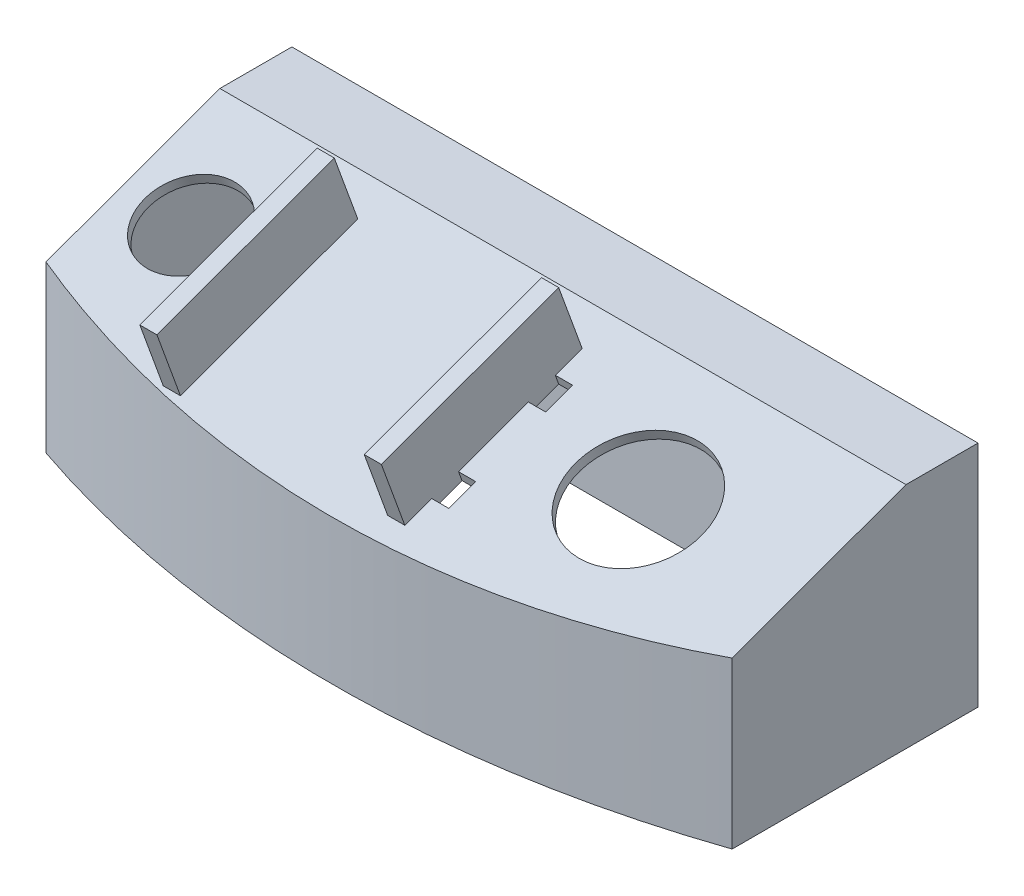
from build123d import *

# Parameters (mm, degrees)
BOSS_EXTRUDE1_DEPTH      = 40
CUT_EXTRUDE1_DEPTH       = 121
SKETCH3_R                = 11
SKETCH3_R_2              = 8.1
CUT_EXTRUDE3_DEPTH       = 1.75
SKETCH5_R                = 15
CUT_EXTRUDE4_DEPTH       = 41.144838819
CUT_EXTRUDE7_DEPTH       = 116.5
SKETCH11_W               = 3
SKETCH11_H               = 33
BOSS_EXTRUDE2_DEPTH      = 12
BOSS_EXTRUDE2_DEPTH_BACK = 1.75
CUT_EXTRUDE8_REACH       = 51.224
BOSS_EXTRUDE3_DEPTH      = 3


with BuildPart() as part:
    # Sketch1 → Boss-Extrude1 (new body)
    with BuildSketch(Plane(origin=(0, 0, 0), x_dir=(1, 0, 0), z_dir=(0, 1, 0))):
        with BuildLine():
            Line((0, 0), (120, 0))
            Line((120, 0), (120, -43))
            ThreePointArc((120, -43), (60, -53), (0, -43))
            Line((0, -43), (0, 0))
        make_face()
    extrude(amount=BOSS_EXTRUDE1_DEPTH)

    # Sketch2 → Cut-Extrude1 (cut, through all)
    with BuildSketch(Plane(origin=(120, 0, 0), x_dir=(0, 0, -1), z_dir=(1, 0, 0))):
        Polygon((-12.593217306, 40), (-53, 25.293133837), (-53, 40), align=None)
    extrude(amount=-CUT_EXTRUDE1_DEPTH, mode=Mode.SUBTRACT)

    # Sketch3 → Cut-Extrude3 (cut)
    with BuildSketch(Plane(origin=(0, 39.368270888, 14.328878778), x_dir=(1, 0, 0), z_dir=(0, 0.939692621, 0.342020143))):
        with Locations((92, -18.169172911)):
            Circle(SKETCH3_R)
        with Locations((12, -16.281893201)):
            Circle(SKETCH3_R_2)
        Polygon((69, -32.152947642), (72, -32.152947642), (72, -27.152947642), (69, -27.152947642), (69, -14.152947642), (72, -14.152947642), (72, -9.152947642), (69, -9.152947642), (69, -4.152947642), (66, -4.152947642), (66, -37.152947642), (69, -37.152947642), align=None)
        Polygon((26.75, -32.152947642), (26.75, -37.152947642), (29.75, -37.152947642), (29.75, -4.152947642), (26.75, -4.152947642), (26.75, -9.152947642), (23.75, -9.152947642), (23.75, -14.152947642), (26.75, -14.152947642), (26.75, -27.152947642), (23.75, -27.152947642), (23.75, -32.152947642), align=None)
    extrude(amount=-CUT_EXTRUDE3_DEPTH, mode=Mode.SUBTRACT)

    # Sketch5 → Cut-Extrude4 (cut, through all)
    with BuildSketch(Plane(origin=(0, 37.723808801, 13.730343527), x_dir=(1, 0, 0), z_dir=(0, 0.939692621, 0.342020143))):
        with Locations((92, -18.169172911)):
            Circle(SKETCH5_R)
    extrude(amount=-CUT_EXTRUDE4_DEPTH, mode=Mode.SUBTRACT)

    # Sketch9 → Cut-Extrude7 (cut)
    with BuildSketch(Plane(origin=(118.25, 0, 0), x_dir=(0, 0, -1), z_dir=(1, 0, 0))):
        Polygon((-1.75, 0), (-1.75, 38.25), (-12.28464509, 38.25), (-41.900468263, 27.470721902), (-41.900468263, 0), align=None)
    extrude(amount=-CUT_EXTRUDE7_DEPTH, mode=Mode.SUBTRACT)

    # Sketch11 → Boss-Extrude2 (add, two sides)
    with BuildSketch(Plane(origin=(0, 39.368270888, 14.328878778), x_dir=(1, 0, 0), z_dir=(0, 0.939692621, 0.342020143))) as boss_extrude2_sk:
        with Locations((28.25, -20.652947642)):
            Rectangle(SKETCH11_W, SKETCH11_H)
        with Locations((67.5, -20.652947642)):
            Rectangle(SKETCH11_W, SKETCH11_H)
    extrude(amount=BOSS_EXTRUDE2_DEPTH)
    extrude(boss_extrude2_sk.sketch, amount=-BOSS_EXTRUDE2_DEPTH_BACK)

    # Cut-Extrude8: up to this face of the body (flat: up to its plane)
    cut_extrude8_end = Plane(part.part.faces().sort_by_distance((59.86605923, 33.016543965, 26.663447373))[0])
    # Sketch13 → Cut-Extrude8 (cut, up to the picked face)
    with BuildSketch(Plane.XZ, mode=Mode.PRIVATE) as cut_extrude8_sk1:
        with BuildLine():
            Line((1.75, 41.900468263), (118.25, 41.900468263))
            ThreePointArc((118.25, 41.900468263), (60, 51.396933895), (1.75, 41.900468263))
        make_face()
    cut_extrude8_tool1 = split(extrude(cut_extrude8_sk1.sketch, amount=-CUT_EXTRUDE8_REACH, mode=Mode.PRIVATE), bisect_by=cut_extrude8_end, keep=Keep.BOTH, mode=Mode.PRIVATE)
    add(cut_extrude8_tool1.solids().sort_by_distance((60, 0, 45.707612))[0], mode=Mode.SUBTRACT)

    # Sketch14 → Boss-Extrude3 (add)
    with BuildSketch(Plane.XZ):
        with BuildLine():
            Line((1.75, 1.75), (21.75, 1.75))
            Line((21.75, 1.75), (21.75, 47.363800311))
            ThreePointArc((21.75, 47.363800311), (11.672735446, 44.914982019), (1.75, 41.900468263))
            Line((1.75, 41.900468263), (1.75, 1.75))
        make_face()
        with BuildLine():
            Line((118.25, 1.75), (118.25, 41.900468263))
            ThreePointArc((118.25, 41.900468263), (108.327264554, 44.914982019), (98.25, 47.363800311))
            Line((98.25, 47.363800311), (98.25, 1.75))
            Line((98.25, 1.75), (118.25, 1.75))
        make_face()
    extrude(amount=-BOSS_EXTRUDE3_DEPTH)


solid = part.part
